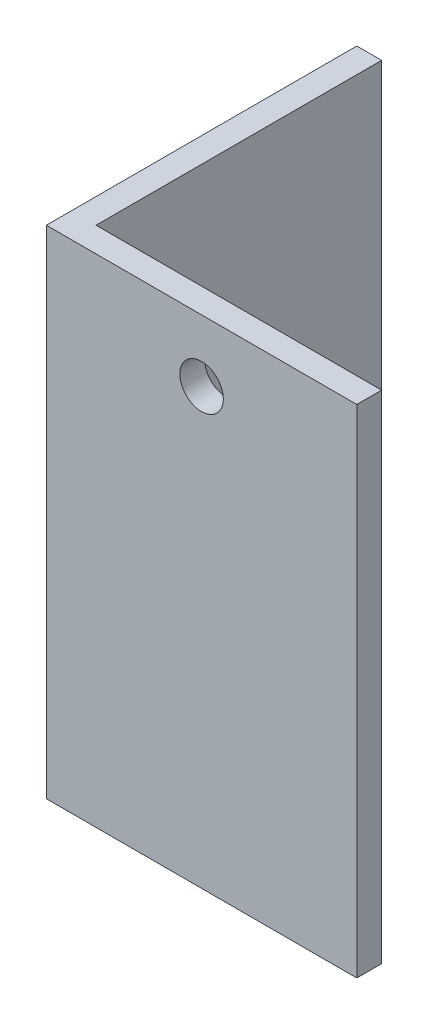
from build123d import *

# Parameters (mm, degrees)
BOSS_EXTRUDE1_DEPTH = 40
SKETCH2_R           = 1.75
CUT_EXTRUDE1_DEPTH  = 50
SKETCH3_R           = 1.75
CUT_EXTRUDE2_DEPTH  = 50


with BuildPart() as part:
    # Sketch1 → Boss-Extrude1 (new body)
    with BuildSketch(Plane(origin=(0, 0, 0), x_dir=(1, 0, 0), z_dir=(0, 1, 0))):
        Polygon((0, 0), (25, 0), (25, 2), (2, 2), (2, 25), (0, 25), align=None)
    extrude(amount=BOSS_EXTRUDE1_DEPTH)

    # Sketch2 → Cut-Extrude1 (cut)
    with BuildSketch(Plane(origin=(0, 0, 0), x_dir=(0, 0, -1), z_dir=(1, 0, 0))):
        with Locations((10, 5)):
            Circle(SKETCH2_R)
    extrude(amount=CUT_EXTRUDE1_DEPTH, mode=Mode.SUBTRACT)

    # Sketch3 → Cut-Extrude2 (cut)
    with BuildSketch(Plane(origin=(0, 0, 0), x_dir=(-1, 0, 0), z_dir=(0, 0, -1))):
        with Locations((-12.5, 35)):
            Circle(SKETCH3_R)
    extrude(amount=CUT_EXTRUDE2_DEPTH, mode=Mode.SUBTRACT)


solid = part.part
